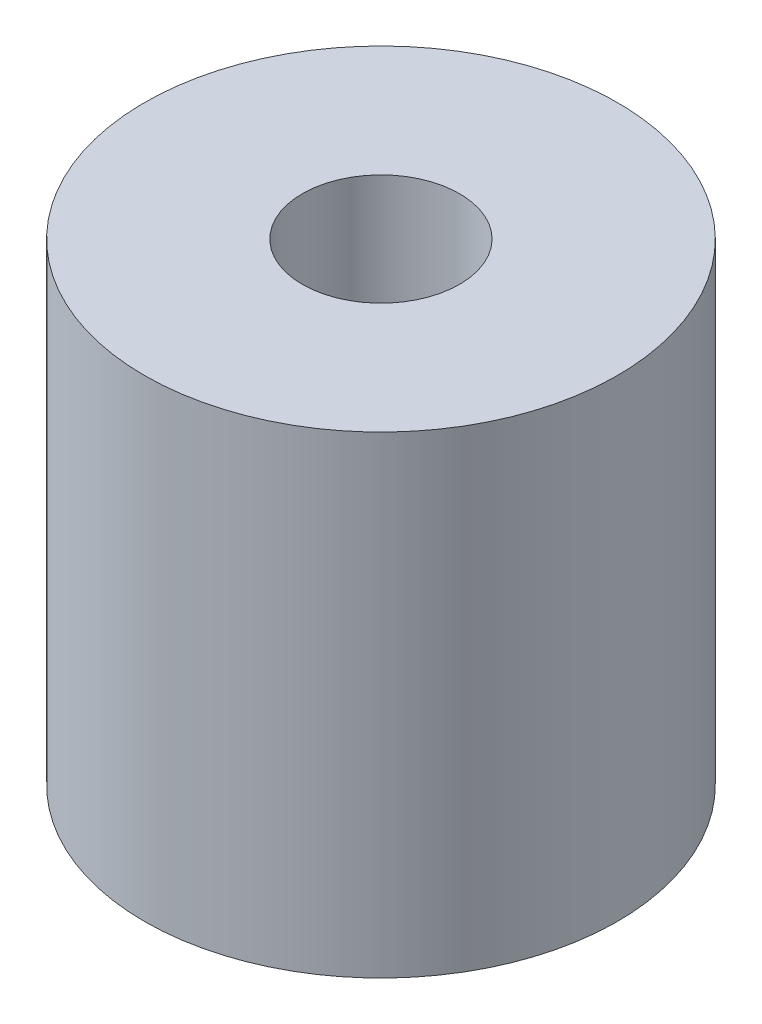
from build123d import *

# Parameters (mm, degrees)
SKETCH1_R           = 12.7
SKETCH1_R_2         = 4.22275
BOSS_EXTRUDE1_DEPTH = 25.4


with BuildPart() as part:
    # Sketch1 → Boss-Extrude1 (new body)
    with BuildSketch(Plane(origin=(0, 0, 0), x_dir=(1, 0, 0), z_dir=(0, 1, 0))):
        Circle(SKETCH1_R)
        Circle(SKETCH1_R_2, mode=Mode.SUBTRACT)
    extrude(amount=BOSS_EXTRUDE1_DEPTH)


solid = part.part
